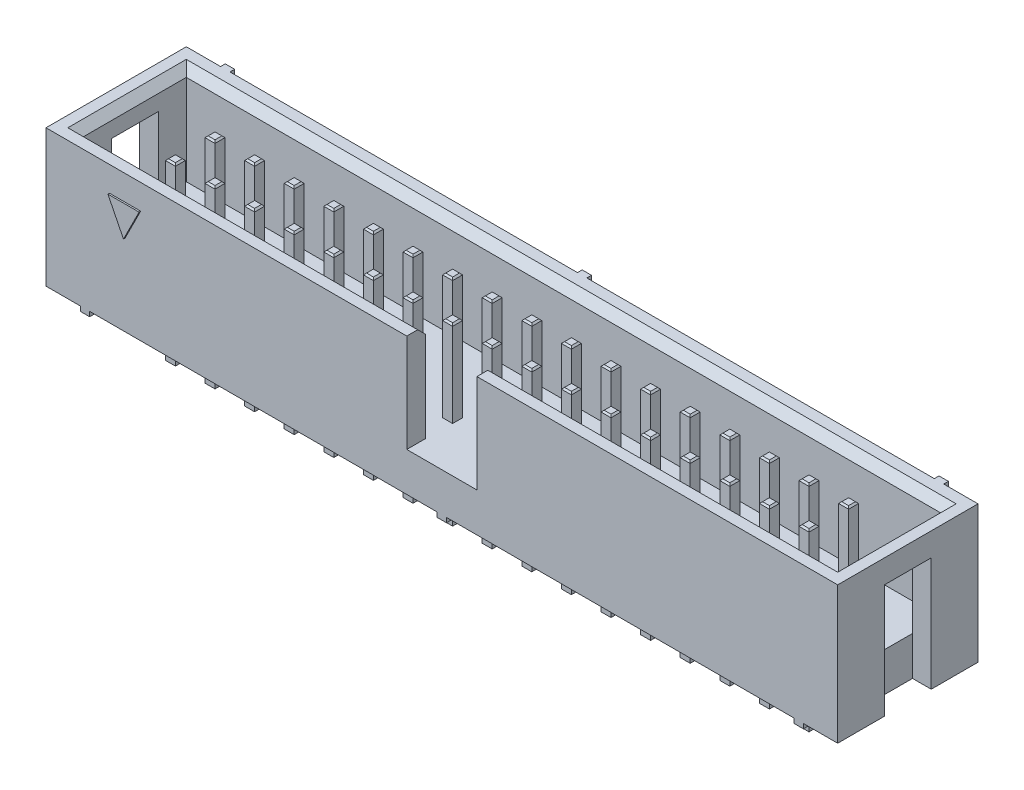
from build123d import *

# Parameters (mm, degrees)
BOSS_EXTRUDE1_START      = 0.3
SKETCH1_W                = 50.78
SKETCH1_H                = 9
BOSS_EXTRUDE1_DEPTH      = 8.8
SKETCH1_3_W              = 0.6
SKETCH1_3_H              = 0.3
BOSS_EXTRUDE2_DEPTH      = 9.1
CUT_EXTRUDE1_START       = 9.1
SKETCH1_4_W              = 48.38
SKETCH1_4_H              = 6.6
SKETCH1_4_W_2            = 4.5
SKETCH1_4_H_2            = 1.2
CUT_EXTRUDE1_DEPTH       = 6.3
CUT_EXTRUDE2_START       = 0.3
SKETCH1_5_W              = 1.2
SKETCH1_5_H              = 3
CUT_EXTRUDE2_DEPTH       = 7.3
BOSS_EXTRUDE3_REACH      = 11.3
SKETCH3_W                = 0.6
SKETCH3_H                = 0.3
CHAMFER2_SIZE            = 0.5
SKETCH4_W                = 0.64
SKETCH4_H                = 0.64
CUT_EXTRUDE4_DEPTH       = 10.1
LPATTERN1_COUNT          = 17
LPATTERN1_PITCH          = 2.54
BOSS_EXTRUDE5_DEPTH      = 0.1
SKETCH5_W                = 0.64
SKETCH5_H                = 0.64
BOSS_EXTRUDE4_DEPTH      = 8.3
BOSS_EXTRUDE4_DEPTH_BACK = 3
CHAMFER3_SIZE            = 0.1
LPATTERN3_COUNT          = 17
LPATTERN3_PITCH          = 2.54
LPATTERN3_2_COUNT        = 2
LPATTERN3_2_PITCH        = 2.54


with BuildPart() as part:
    # Sketch1 → Boss-Extrude1 (new body)
    with BuildSketch(Plane(origin=(0, 0, 0), x_dir=(1, 0, 0), z_dir=(0, 1, 0)).offset(BOSS_EXTRUDE1_START)):
        Rectangle(SKETCH1_W, SKETCH1_H)
    extrude(amount=BOSS_EXTRUDE1_DEPTH)

    # Sketch1_3 → Boss-Extrude2 (add)
    with BuildSketch(Plane(origin=(0, 0, 0), x_dir=(1, 0, 0), z_dir=(0, 1, 0))):
        with Locations((22.89, 4.65)):
            Rectangle(SKETCH1_3_W, SKETCH1_3_H)
        with Locations((0, 4.65)):
            Rectangle(SKETCH1_3_W, SKETCH1_3_H)
        with Locations((-22.89, 4.65)):
            Rectangle(SKETCH1_3_W, SKETCH1_3_H)
    extrude(amount=BOSS_EXTRUDE2_DEPTH)

    # Sketch1_4 → Cut-Extrude1 (cut)
    with BuildSketch(Plane(origin=(0, 0, 0), x_dir=(1, 0, 0), z_dir=(0, 1, 0)).offset(CUT_EXTRUDE1_START)):
        Rectangle(SKETCH1_4_W, SKETCH1_4_H)
        with Locations((0, -3.9)):
            Rectangle(SKETCH1_4_W_2, SKETCH1_4_H_2)
    extrude(amount=-CUT_EXTRUDE1_DEPTH, mode=Mode.SUBTRACT)

    # Sketch1_5 → Cut-Extrude2 (cut)
    with BuildSketch(Plane(origin=(0, 0, 0), x_dir=(1, 0, 0), z_dir=(0, 1, 0)).offset(CUT_EXTRUDE2_START)):
        with Locations((-24.79, 0)):
            Rectangle(SKETCH1_5_W, SKETCH1_5_H)
        with Locations((24.79, 0)):
            Rectangle(SKETCH1_5_W, SKETCH1_5_H)
    extrude(amount=CUT_EXTRUDE2_DEPTH, mode=Mode.SUBTRACT)

    # Sketch3 → Boss-Extrude3 (add, up to next)
    with BuildSketch(Plane.XY.offset(4.5), mode=Mode.PRIVATE) as boss_extrude3_sk1:
        with Locations((-22.89, 0.15)):
            Rectangle(SKETCH3_W, SKETCH3_H)
    boss_extrude3_tool1 = extrude(boss_extrude3_sk1.sketch, amount=-BOSS_EXTRUDE3_REACH, mode=Mode.PRIVATE) - part.part
    add(boss_extrude3_tool1.solids().sort_by_distance((-22.89, 0.15, 4.5))[0])
    # Sketch3 → Boss-Extrude3 (add, up to next)
    with BuildSketch(Plane.XY.offset(4.5), mode=Mode.PRIVATE) as boss_extrude3_sk2:
        with Locations((0, 0.15)):
            Rectangle(SKETCH3_W, SKETCH3_H)
    boss_extrude3_tool2 = extrude(boss_extrude3_sk2.sketch, amount=-BOSS_EXTRUDE3_REACH, mode=Mode.PRIVATE) - part.part
    add(boss_extrude3_tool2.solids().sort_by_distance((0, 0.15, 4.5))[0])
    # Sketch3 → Boss-Extrude3 (add, up to next)
    with BuildSketch(Plane.XY.offset(4.5), mode=Mode.PRIVATE) as boss_extrude3_sk3:
        with Locations((22.89, 0.15)):
            Rectangle(SKETCH3_W, SKETCH3_H)
    boss_extrude3_tool3 = extrude(boss_extrude3_sk3.sketch, amount=-BOSS_EXTRUDE3_REACH, mode=Mode.PRIVATE) - part.part
    add(boss_extrude3_tool3.solids().sort_by_distance((22.89, 0.15, 4.5))[0])

    # Chamfer2
    chamfer2_edges = [part.edges().sort_by_distance(p)[0] for p in [
        (-13.22, 9.1, 3.3),
        (24.19, 9.1, 0),
        (13.22, 9.1, 3.3),
        (0, 9.1, -3.3),
        (-24.19, 9.1, 0),
    ]]
    chamfer(chamfer2_edges, length=CHAMFER2_SIZE)

    # Sketch4 → Cut-Extrude4 (cut, through all)
    with BuildSketch(Plane(origin=(0, 0, 0), x_dir=(1, 0, 0), z_dir=(0, 1, 0))):
        with Locations((-20.32, 1.27)):
            Rectangle(SKETCH4_W, SKETCH4_H)
        with Locations((-20.32, -1.27)):
            Rectangle(SKETCH4_W, SKETCH4_H)
    cut_extrude4 = extrude(amount=CUT_EXTRUDE4_DEPTH, mode=Mode.SUBTRACT)

    # LPattern1: Cut-Extrude4 ×17
    with Locations(*[(i * LPATTERN1_PITCH, 0, 0) for i in range(1, LPATTERN1_COUNT)]):
        add(cut_extrude4, mode=Mode.SUBTRACT)

    # Sketch6 → Boss-Extrude5 (add)
    with BuildSketch(Plane.XY.offset(4.5)):
        Polygon((-21.32, 7.5), (-20.32, 5.5), (-19.32, 7.5), align=None)
    extrude(amount=BOSS_EXTRUDE5_DEPTH)


with BuildPart() as body_2:
    # Sketch5 → Boss-Extrude4 (new body, two sides)
    with BuildSketch(Plane(origin=(0, 0, 0), x_dir=(1, 0, 0), z_dir=(0, 1, 0))) as boss_extrude4_sk:
        with Locations((-20.32, -1.27)):
            Rectangle(SKETCH5_W, SKETCH5_H)
    extrude(amount=BOSS_EXTRUDE4_DEPTH)
    extrude(boss_extrude4_sk.sketch, amount=-BOSS_EXTRUDE4_DEPTH_BACK)

    # Chamfer3
    chamfer3_edges = [body_2.edges().sort_by_distance(p)[0] for p in [
        (-20.64, 8.3, 1.27),
        (-20, -3, 1.27),
        (-20.32, 8.3, 1.59),
        (-20, 8.3, 1.27),
        (-20.32, 8.3, 0.95),
        (-20.32, -3, 0.95),
        (-20.64, -3, 1.27),
        (-20.32, -3, 1.59),
    ]]
    chamfer(chamfer3_edges, length=CHAMFER3_SIZE)


with BuildPart() as lpattern3_1:
    # LPattern3: pattern copy
    add(body_2.part.moved(Location(Vector(1, 0, 0) * (1 * LPATTERN3_PITCH))))


with BuildPart() as lpattern3_2:
    # LPattern3: pattern copy
    add(body_2.part.moved(Location(Vector(1, 0, 0) * (2 * LPATTERN3_PITCH))))


with BuildPart() as lpattern3_3:
    # LPattern3: pattern copy
    add(body_2.part.moved(Location(Vector(1, 0, 0) * (3 * LPATTERN3_PITCH))))


with BuildPart() as lpattern3_4:
    # LPattern3: pattern copy
    add(body_2.part.moved(Location(Vector(1, 0, 0) * (4 * LPATTERN3_PITCH))))


with BuildPart() as lpattern3_5:
    # LPattern3: pattern copy
    add(body_2.part.moved(Location(Vector(1, 0, 0) * (5 * LPATTERN3_PITCH))))


with BuildPart() as lpattern3_6:
    # LPattern3: pattern copy
    add(body_2.part.moved(Location(Vector(1, 0, 0) * (6 * LPATTERN3_PITCH))))


with BuildPart() as lpattern3_7:
    # LPattern3: pattern copy
    add(body_2.part.moved(Location(Vector(1, 0, 0) * (7 * LPATTERN3_PITCH))))


with BuildPart() as lpattern3_8:
    # LPattern3: pattern copy
    add(body_2.part.moved(Location(Vector(1, 0, 0) * (8 * LPATTERN3_PITCH))))


with BuildPart() as lpattern3_9:
    # LPattern3: pattern copy
    add(body_2.part.moved(Location(Vector(1, 0, 0) * (9 * LPATTERN3_PITCH))))


with BuildPart() as lpattern3_10:
    # LPattern3: pattern copy
    add(body_2.part.moved(Location(Vector(1, 0, 0) * (10 * LPATTERN3_PITCH))))


with BuildPart() as lpattern3_11:
    # LPattern3: pattern copy
    add(body_2.part.moved(Location(Vector(1, 0, 0) * (11 * LPATTERN3_PITCH))))


with BuildPart() as lpattern3_12:
    # LPattern3: pattern copy
    add(body_2.part.moved(Location(Vector(1, 0, 0) * (12 * LPATTERN3_PITCH))))


with BuildPart() as lpattern3_13:
    # LPattern3: pattern copy
    add(body_2.part.moved(Location(Vector(1, 0, 0) * (13 * LPATTERN3_PITCH))))


with BuildPart() as lpattern3_14:
    # LPattern3: pattern copy
    add(body_2.part.moved(Location(Vector(1, 0, 0) * (14 * LPATTERN3_PITCH))))


with BuildPart() as lpattern3_15:
    # LPattern3: pattern copy
    add(body_2.part.moved(Location(Vector(1, 0, 0) * (15 * LPATTERN3_PITCH))))


with BuildPart() as lpattern3_16:
    # LPattern3: pattern copy
    add(body_2.part.moved(Location(Vector(1, 0, 0) * (16 * LPATTERN3_PITCH))))


with BuildPart() as lpattern3_2_1:
    # LPattern3 2: pattern copy
    add(body_2.part.moved(Location(Vector(0, 0, -1) * (1 * LPATTERN3_2_PITCH))))


with BuildPart() as lpattern3_2_2:
    # LPattern3 2: pattern copy
    add(lpattern3_1.part.moved(Location(Vector(0, 0, -1) * (1 * LPATTERN3_2_PITCH))))


with BuildPart() as lpattern3_2_3:
    # LPattern3 2: pattern copy
    add(lpattern3_2.part.moved(Location(Vector(0, 0, -1) * (1 * LPATTERN3_2_PITCH))))


with BuildPart() as lpattern3_2_4:
    # LPattern3 2: pattern copy
    add(lpattern3_3.part.moved(Location(Vector(0, 0, -1) * (1 * LPATTERN3_2_PITCH))))


with BuildPart() as lpattern3_2_5:
    # LPattern3 2: pattern copy
    add(lpattern3_4.part.moved(Location(Vector(0, 0, -1) * (1 * LPATTERN3_2_PITCH))))


with BuildPart() as lpattern3_2_6:
    # LPattern3 2: pattern copy
    add(lpattern3_5.part.moved(Location(Vector(0, 0, -1) * (1 * LPATTERN3_2_PITCH))))


with BuildPart() as lpattern3_2_7:
    # LPattern3 2: pattern copy
    add(lpattern3_6.part.moved(Location(Vector(0, 0, -1) * (1 * LPATTERN3_2_PITCH))))


with BuildPart() as lpattern3_2_8:
    # LPattern3 2: pattern copy
    add(lpattern3_7.part.moved(Location(Vector(0, 0, -1) * (1 * LPATTERN3_2_PITCH))))


with BuildPart() as lpattern3_2_9:
    # LPattern3 2: pattern copy
    add(lpattern3_8.part.moved(Location(Vector(0, 0, -1) * (1 * LPATTERN3_2_PITCH))))


with BuildPart() as lpattern3_2_10:
    # LPattern3 2: pattern copy
    add(lpattern3_9.part.moved(Location(Vector(0, 0, -1) * (1 * LPATTERN3_2_PITCH))))


with BuildPart() as lpattern3_2_11:
    # LPattern3 2: pattern copy
    add(lpattern3_10.part.moved(Location(Vector(0, 0, -1) * (1 * LPATTERN3_2_PITCH))))


with BuildPart() as lpattern3_2_12:
    # LPattern3 2: pattern copy
    add(lpattern3_11.part.moved(Location(Vector(0, 0, -1) * (1 * LPATTERN3_2_PITCH))))


with BuildPart() as lpattern3_2_13:
    # LPattern3 2: pattern copy
    add(lpattern3_12.part.moved(Location(Vector(0, 0, -1) * (1 * LPATTERN3_2_PITCH))))


with BuildPart() as lpattern3_2_14:
    # LPattern3 2: pattern copy
    add(lpattern3_13.part.moved(Location(Vector(0, 0, -1) * (1 * LPATTERN3_2_PITCH))))


with BuildPart() as lpattern3_2_15:
    # LPattern3 2: pattern copy
    add(lpattern3_14.part.moved(Location(Vector(0, 0, -1) * (1 * LPATTERN3_2_PITCH))))


with BuildPart() as lpattern3_2_16:
    # LPattern3 2: pattern copy
    add(lpattern3_15.part.moved(Location(Vector(0, 0, -1) * (1 * LPATTERN3_2_PITCH))))


with BuildPart() as lpattern3_2_17:
    # LPattern3 2: pattern copy
    add(lpattern3_16.part.moved(Location(Vector(0, 0, -1) * (1 * LPATTERN3_2_PITCH))))


solid = Compound([part.part, body_2.part, lpattern3_1.part, lpattern3_2.part, lpattern3_3.part, lpattern3_4.part, lpattern3_5.part, lpattern3_6.part, lpattern3_7.part, lpattern3_8.part, lpattern3_9.part, lpattern3_10.part, lpattern3_11.part, lpattern3_12.part, lpattern3_13.part, lpattern3_14.part, lpattern3_15.part, lpattern3_16.part, lpattern3_2_1.part, lpattern3_2_2.part, lpattern3_2_3.part, lpattern3_2_4.part, lpattern3_2_5.part, lpattern3_2_6.part, lpattern3_2_7.part, lpattern3_2_8.part, lpattern3_2_9.part, lpattern3_2_10.part, lpattern3_2_11.part, lpattern3_2_12.part, lpattern3_2_13.part, lpattern3_2_14.part, lpattern3_2_15.part, lpattern3_2_16.part, lpattern3_2_17.part])
